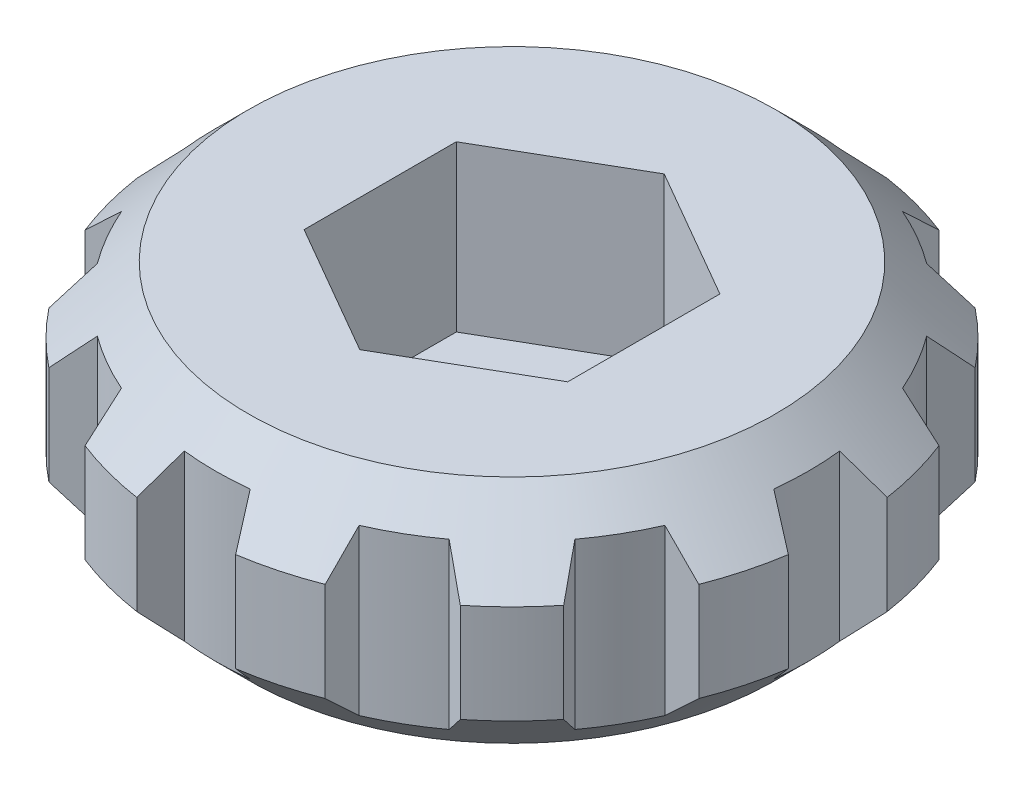
from build123d import *

# Parameters (mm, degrees)
ODEBRAT_VYSUNUT_M1_DEPTH = 5
ODEBRAT_VYSUNUT_M2_DEPTH = 8
KRUHOV_POLE1_COUNT       = 12


with BuildPart() as part:
    # Skica1 → Rotovat1 (revolve)
    with BuildSketch(Plane(origin=(0, 0, 0), x_dir=(0, 0, -1), z_dir=(1, 0, 0))):
        Polygon((2.75, 0), (8, 0), (10, 2), (10, 5), (8, 7), (2.75, 7), align=None)
    revolve(axis=Axis((0, 0, 0), (0, 1, 0)))

    # Skica2 → Odebrat vysunutím1 (cut)
    with BuildSketch(Plane(origin=(0, 7, 0), x_dir=(1, 0, 0), z_dir=(0, 1, 0))):
        Polygon((-4, -2.309401077), (0, -4.618802154), (4, -2.309401077), (4, 2.309401077), (0, 4.618802154), (-4, 2.309401077), align=None)
    extrude(amount=-ODEBRAT_VYSUNUT_M1_DEPTH, mode=Mode.SUBTRACT)

    # Skica3 → Odebrat vysunutím2 (cut, through all)
    with BuildSketch(Plane(origin=(0, 7, 0), x_dir=(1, 0, 0), z_dir=(0, 1, 0))):
        with BuildLine():
            Line((-1, 8.94427191), (-1.5, 9.886859967))
            ThreePointArc((-1.5, 9.886859967), (0, 10), (1.5, 9.886859967))
            Line((1.5, 9.886859967), (1, 8.94427191))
            ThreePointArc((1, 8.94427191), (0, 9), (-1, 8.94427191))
        make_face()
    odebrat_vysunut_m2 = extrude(amount=-ODEBRAT_VYSUNUT_M2_DEPTH, mode=Mode.SUBTRACT)

    # Kruhové pole1: Odebrat vysunutím2 ×12 about axis
    kruhov_pole1_axis = Axis((0, 0, 0), (0, 1, 0))
    for i in range(1, KRUHOV_POLE1_COUNT):
        add(odebrat_vysunut_m2.rotate(kruhov_pole1_axis, i * 360 / KRUHOV_POLE1_COUNT), mode=Mode.SUBTRACT)


solid = part.part
